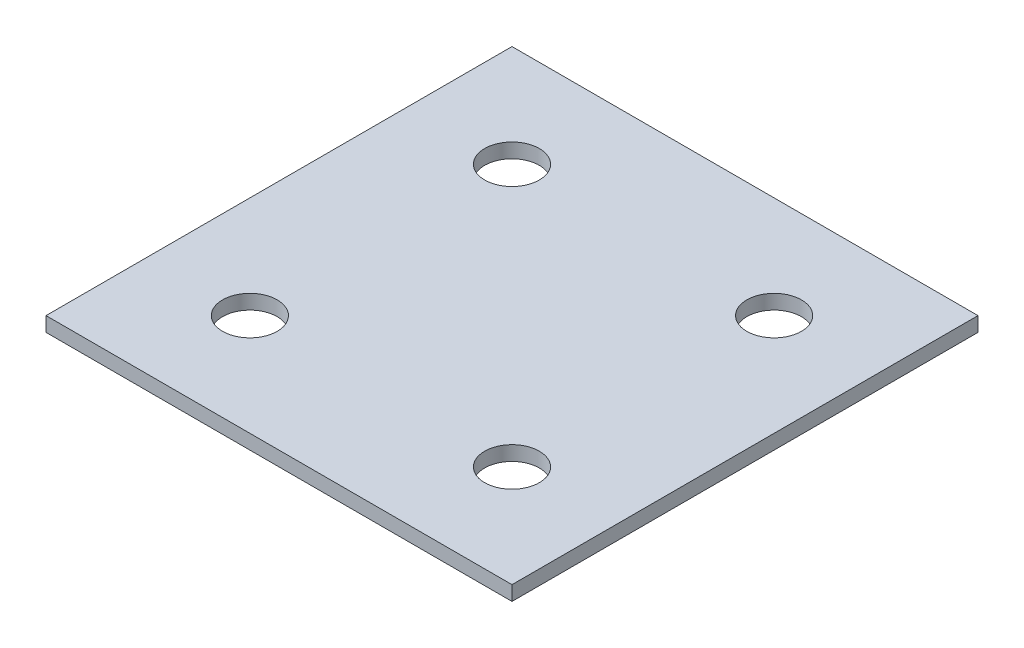
from build123d import *

# Parameters (mm, degrees)
SKETCH2_W           = 203.2
SKETCH2_H           = 203.2
SKETCH2_R           = 11.90625
BOSS_EXTRUDE1_DEPTH = 6.35


with BuildPart() as part:
    # Sketch2 → Boss-Extrude1 (new body)
    with BuildSketch(Plane(origin=(0, 0, 0), x_dir=(1, 0, 0), z_dir=(0, 1, 0))):
        with Locations((101.6, 101.6)):
            Rectangle(SKETCH2_W, SKETCH2_H)
        with Locations((44.45, 158.75)):
            Circle(SKETCH2_R, mode=Mode.SUBTRACT)
        with Locations((44.45, 44.45)):
            Circle(SKETCH2_R, mode=Mode.SUBTRACT)
        with Locations((158.75, 158.75)):
            Circle(SKETCH2_R, mode=Mode.SUBTRACT)
        with Locations((158.75, 44.45)):
            Circle(SKETCH2_R, mode=Mode.SUBTRACT)
    extrude(amount=BOSS_EXTRUDE1_DEPTH)


solid = part.part
